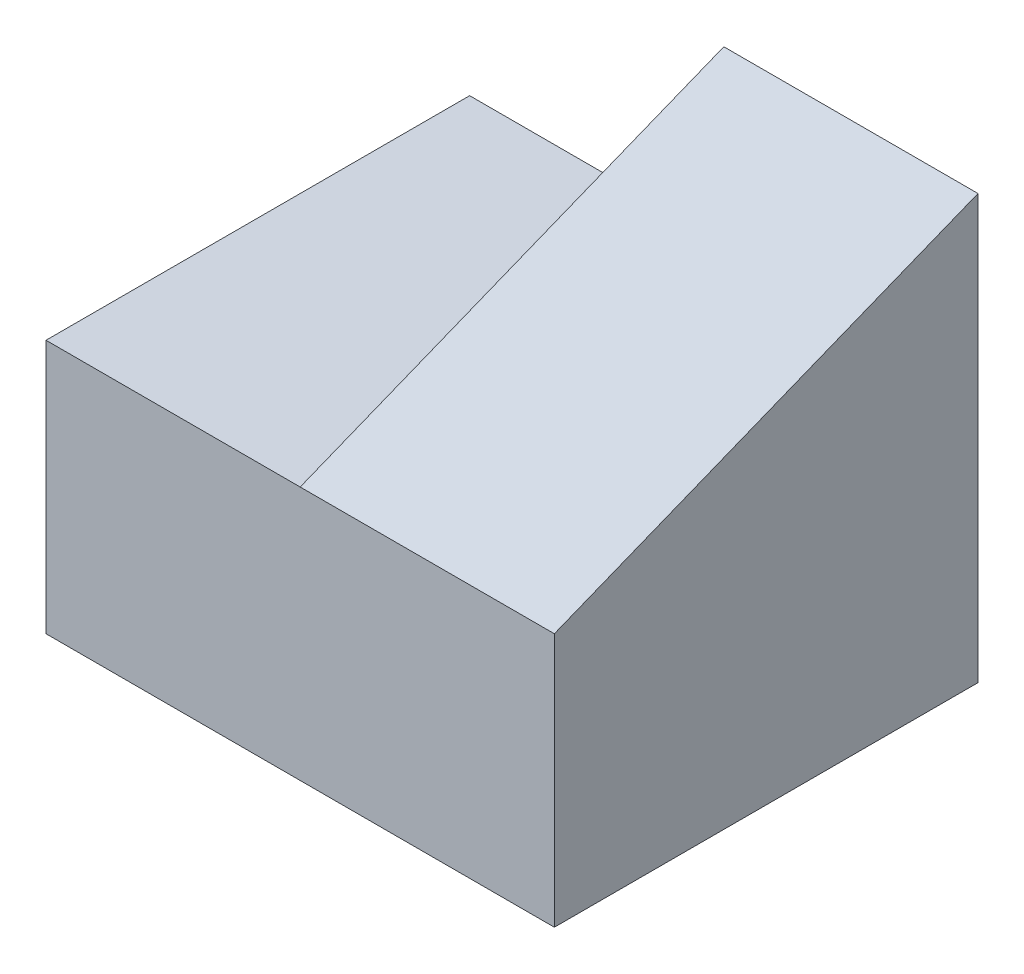
from build123d import *

# Parameters (mm, degrees)
SKETCH1_W           = 30
SKETCH1_H           = 15
BOSS_EXTRUDE1_DEPTH = 25
BOSS_EXTRUDE2_DEPTH = 15


with BuildPart() as part:
    # Sketch1 → Boss-Extrude1 (new body)
    with BuildSketch(Plane.XY):
        with Locations((15, 7.5)):
            Rectangle(SKETCH1_W, SKETCH1_H)
    extrude(amount=BOSS_EXTRUDE1_DEPTH)

    # Sketch2 → Boss-Extrude2 (add)
    with BuildSketch(Plane(origin=(30, 0, 0), x_dir=(0, 0, -1), z_dir=(1, 0, 0))):
        Polygon((0, 15), (0, 25), (-25, 15), align=None)
    extrude(amount=-BOSS_EXTRUDE2_DEPTH)


solid = part.part
